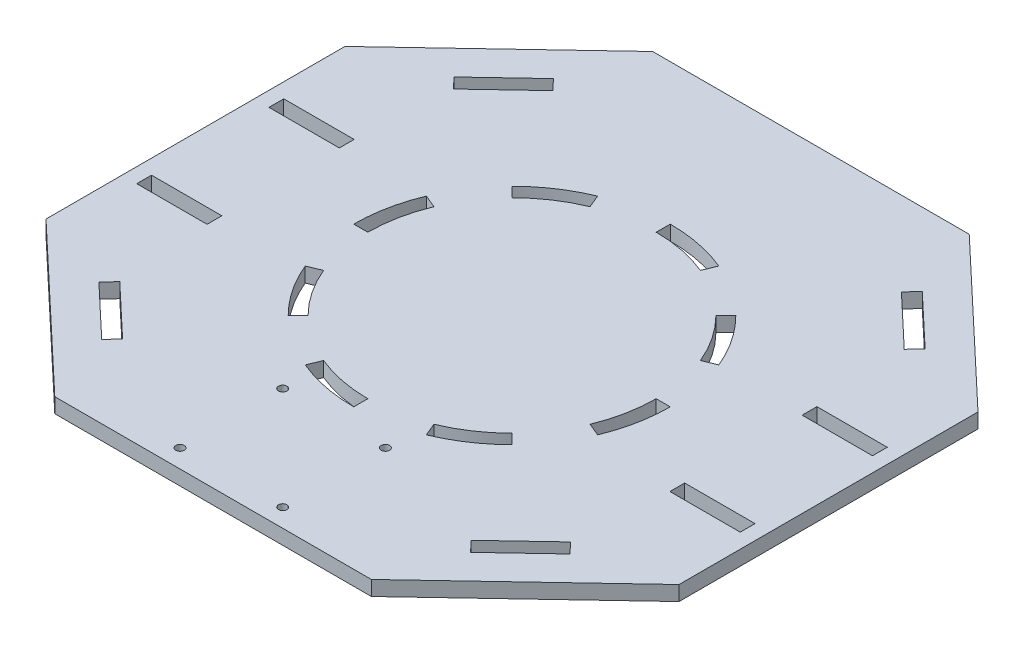
from build123d import *

# Parameters (mm, degrees)
SKETCH1_W           = 228.6
SKETCH1_H           = 215.9
BOSS_EXTRUDE1_DEPTH = 5.334
SKETCH8_W           = 25.4
SKETCH8_H           = 5.334
CUT_EXTRUDE2_DEPTH  = 6.334
SKETCH11_R          = 1.524
CUT_EXTRUDE4_DEPTH  = 6.334
CUT_EXTRUDE5_DEPTH  = 6.334
CUT_EXTRUDE6_DEPTH  = 6.334
CIRPATTERN1_COUNT   = 8
CUT_EXTRUDE7_DEPTH  = 6.334


with BuildPart() as part:
    # Sketch1 → Boss-Extrude1 (new body)
    with BuildSketch(Plane(origin=(0, 0, 0), x_dir=(1, 0, 0), z_dir=(0, 1, 0))):
        with Locations((114.3, 107.95)):
            Rectangle(SKETCH1_W, SKETCH1_H)
    extrude(amount=BOSS_EXTRUDE1_DEPTH)

    # Sketch8 → Cut-Extrude2 (cut, through all)
    with BuildSketch(Plane(origin=(0, 5.334, 0), x_dir=(1, 0, 0), z_dir=(0, 1, 0))):
        with Locations((18.034, 131.826)):
            Rectangle(SKETCH8_W, SKETCH8_H)
        with Locations((210.566, 131.826)):
            Rectangle(SKETCH8_W, SKETCH8_H)
        with Locations((210.566, 84.074)):
            Rectangle(SKETCH8_W, SKETCH8_H)
        with Locations((18.034, 84.074)):
            Rectangle(SKETCH8_W, SKETCH8_H)
    extrude(amount=-CUT_EXTRUDE2_DEPTH, mode=Mode.SUBTRACT)

    # Sketch11 → Cut-Extrude4 (cut, through all)
    with BuildSketch(Plane(origin=(0, 5.334, 0), x_dir=(1, 0, 0), z_dir=(0, 1, 0))):
        with Locations((95.758, 6.604)):
            Circle(SKETCH11_R)
        with Locations((132.842, 6.604)):
            Circle(SKETCH11_R)
        with Locations((132.842, 43.688)):
            Circle(SKETCH11_R)
        with Locations((95.758, 43.688)):
            Circle(SKETCH11_R)
    extrude(amount=-CUT_EXTRUDE4_DEPTH, mode=Mode.SUBTRACT)

    # Sketch13 → Cut-Extrude5 (cut, through all)
    with BuildSketch(Plane(origin=(0, 5.334, 0), x_dir=(1, 0, 0), z_dir=(0, 1, 0))):
        Polygon((0, 215.9), (0, 161.925), (57.15, 215.9), align=None)
        Polygon((228.6, 161.925), (171.45, 215.9), (228.6, 215.9), align=None)
        Polygon((228.6, 0), (228.6, 53.975), (171.45, 0), align=None)
        Polygon((0, 53.975), (57.15, 0), (0, 0), align=None)
    extrude(amount=-CUT_EXTRUDE5_DEPTH, mode=Mode.SUBTRACT)

    # Sketch6 → Cut-Extrude6 (cut, through all)
    with BuildSketch(Plane(origin=(0, 5.334, 0), x_dir=(1, 0, 0), z_dir=(0, 1, 0))):
        with BuildLine():
            Line((114.3, 165.1), (114.3, 160.02))
            ThreePointArc((114.3, 160.02), (124.427414599, 159.025633853), (134.168028422, 156.080513675))
            ThreePointArc((134.168028422, 156.080513675), (134.197181023, 156.068469295), (134.226326323, 156.056407258))
            Line((134.226326323, 156.056407258), (136.17035816, 160.749715283))
            ThreePointArc((136.17035816, 160.749715283), (125.449411903, 164.001878775), (114.3, 165.1))
        make_face()
    cut_extrude6 = extrude(amount=-CUT_EXTRUDE6_DEPTH, mode=Mode.SUBTRACT)

    # CirPattern1: Cut-Extrude6 ×8 about axis
    cirpattern1_axis = Axis((114.3, 0, -107.95), (0, 1, 0))
    for i in range(1, CIRPATTERN1_COUNT):
        add(cut_extrude6.rotate(cirpattern1_axis, i * 360 / CIRPATTERN1_COUNT), mode=Mode.SUBTRACT)

    # Sketch16 → Cut-Extrude7 (cut, through all)
    with BuildSketch(Plane(origin=(0, 5.334, 0), x_dir=(1, 0, 0), z_dir=(0, 1, 0))):
        Polygon((180.893807675, 189.512113449), (199.35994175, 172.071875712), (195.697491825, 168.193987556), (177.23135775, 185.634225293), align=None)
        Polygon((47.706192325, 189.512113449), (51.36864225, 185.634225293), (32.902508175, 168.193987556), (29.24005825, 172.071875712), align=None)
        Polygon((47.706192325, 26.387886551), (29.24005825, 43.828124288), (32.902508175, 47.706012444), (51.36864225, 30.265774707), align=None)
        Polygon((180.893807675, 26.387886551), (177.23135775, 30.265774707), (195.697491825, 47.706012444), (199.35994175, 43.828124288), align=None)
    extrude(amount=-CUT_EXTRUDE7_DEPTH, mode=Mode.SUBTRACT)


solid = part.part
